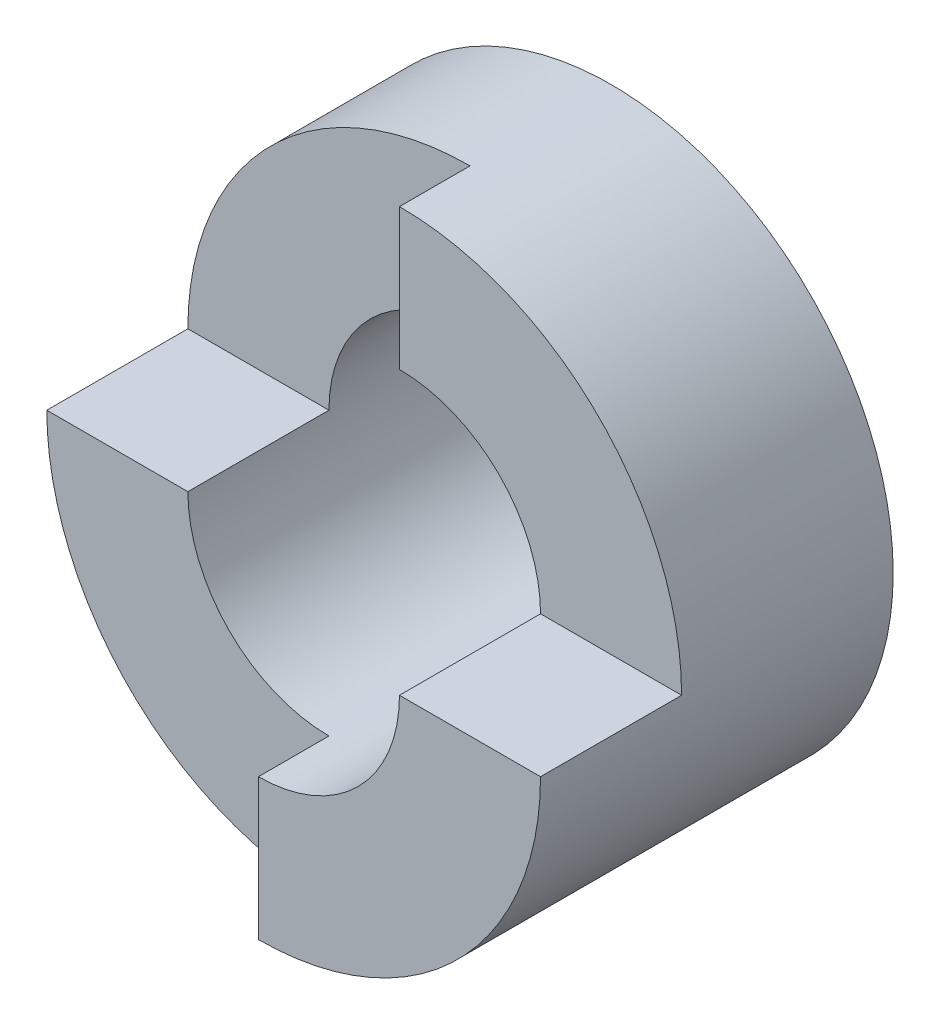
from build123d import *

# Parameters (mm, degrees)
SKETCH1_R           = 4
SKETCH1_R_2         = 2
BOSS_EXTRUDE1_DEPTH = 5
CUT_EXTRUDE1_DEPTH  = 5
SKETCH3_W           = 4
SKETCH3_H           = 1
CUT_EXTRUDE2_DEPTH  = 5


with BuildPart() as part:
    # Sketch1 → Boss-Extrude1 (new body)
    with BuildSketch(Plane.XY):
        Circle(SKETCH1_R)
        Circle(SKETCH1_R_2, mode=Mode.SUBTRACT)
    extrude(amount=BOSS_EXTRUDE1_DEPTH)

    # Sketch2 → Cut-Extrude1 (cut)
    with BuildSketch(Plane(origin=(0, 0, 0), x_dir=(1, 0, 0), z_dir=(0, 1, 0))):
        Polygon((-4, -2), (0, -2), (0, -3), (4, -3), (4, -5), (-4, -5), align=None)
    extrude(amount=CUT_EXTRUDE1_DEPTH, mode=Mode.SUBTRACT)

    # Sketch3 → Cut-Extrude2 (cut)
    with BuildSketch(Plane(origin=(0, 0, 0), x_dir=(1, 0, 0), z_dir=(0, 1, 0))):
        with Locations((-2, -4.5)):
            Rectangle(SKETCH3_W, SKETCH3_H)
    extrude(amount=-CUT_EXTRUDE2_DEPTH, mode=Mode.SUBTRACT)


solid = part.part
